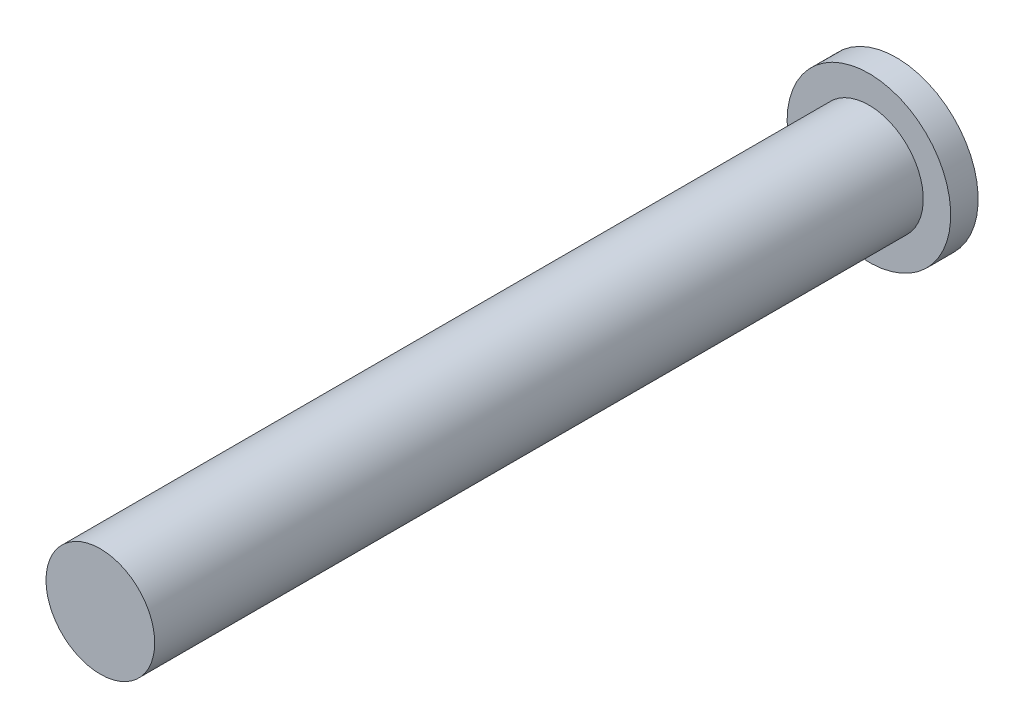
from build123d import *

# Parameters (mm, degrees)
SKETCH1_R           = 4.95
BOSS_EXTRUDE1_DEPTH = 70
SKETCH3_R           = 7.45
BOSS_EXTRUDE2_DEPTH = 2.5


with BuildPart() as part:
    # Sketch1 → Boss-Extrude1 (new body)
    with BuildSketch(Plane.XY):
        Circle(SKETCH1_R)
    extrude(amount=BOSS_EXTRUDE1_DEPTH)

    # Sketch3 → Boss-Extrude2 (add)
    with BuildSketch(Plane(origin=(0, 0, 0), x_dir=(-1, 0, 0), z_dir=(0, 0, -1))):
        Circle(SKETCH3_R)
    extrude(amount=BOSS_EXTRUDE2_DEPTH)


solid = part.part
